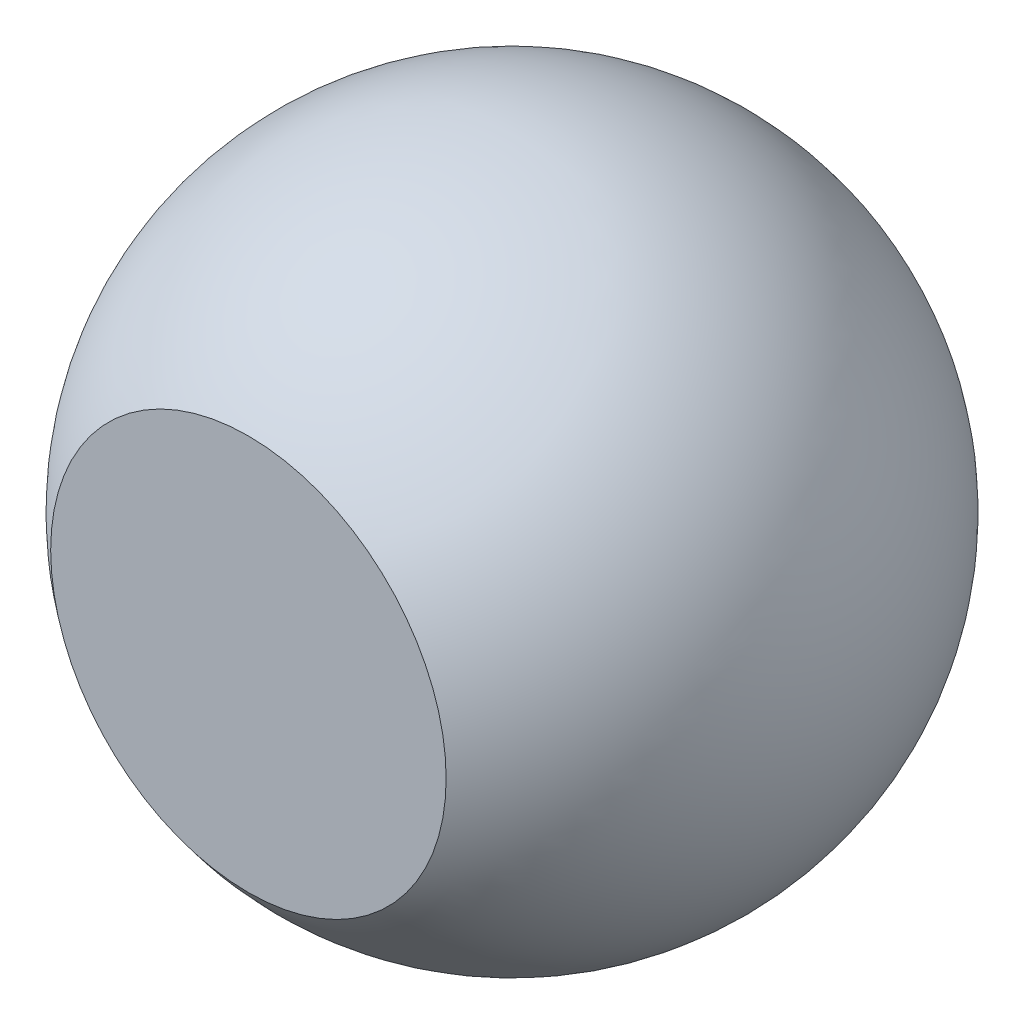
from build123d import *


with BuildPart() as part:
    # Sketch1 → Revolve1 (revolve)
    with BuildSketch(Plane(origin=(0, 0, 0), x_dir=(1, 0, 0), z_dir=(0, 1, 0))):
        with BuildLine():
            Line((0, 0.2), (0, -0.2))
            Line((0, -0.2), (0.15, -0.2))
            ThreePointArc((0.15, -0.2), (0.25, 0), (0.15, 0.2))
            Line((0.15, 0.2), (0, 0.2))
        make_face()
    revolve(axis=Axis((0, 0, -0.2), (0, 0, 1)))


solid = part.part
